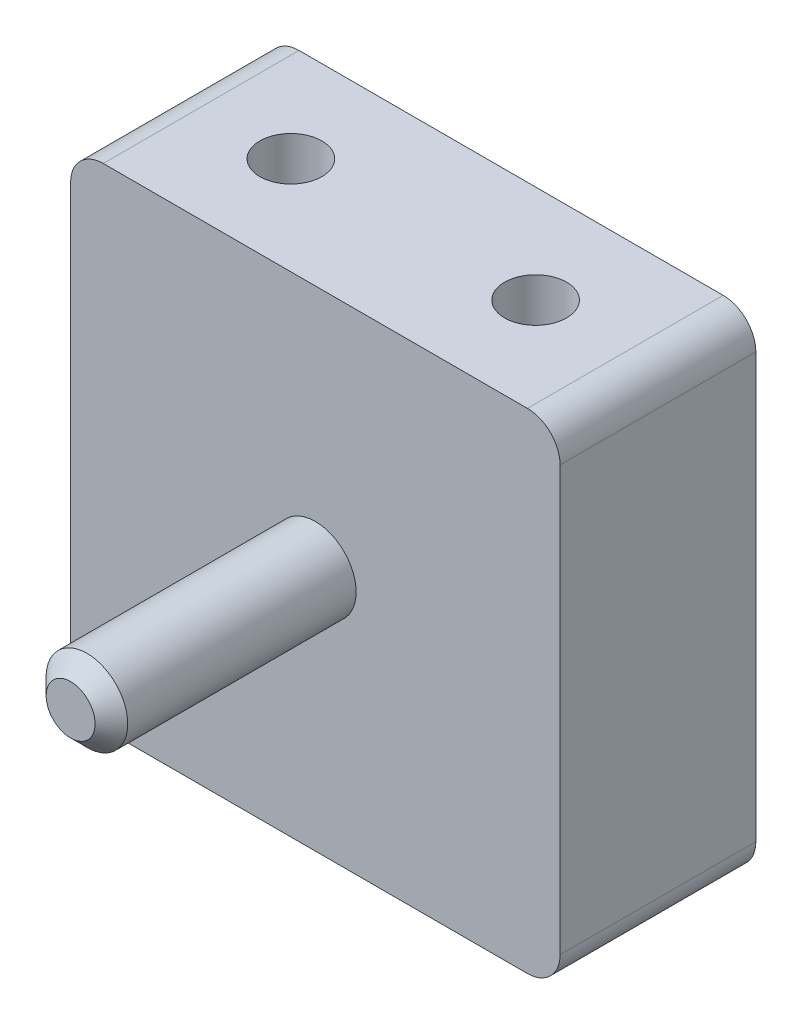
from build123d import *

# Parameters (mm, degrees)
SKETCH1_W           = 38.1
SKETCH1_H           = 38.1
SKETCH1_R           = 1.5875
BOSS_EXTRUDE2_DEPTH = 15.24
SKETCH3_R           = 3.175
BOSS_EXTRUDE3_DEPTH = 19.05
FILLET2_R           = 2.54
CHAMFER1_SIZE       = 1.27
SKETCH4_R           = 2.413
CUT_EXTRUDE2_DEPTH  = 7.62
SKETCH5_R           = 2.413
CUT_EXTRUDE3_DEPTH  = 7.62
SKETCH6_R           = 2.413
CUT_EXTRUDE4_DEPTH  = 39.1


with BuildPart() as part:
    # Sketch1 → Boss-Extrude2 (new body)
    with BuildSketch(Plane.XY):
        Rectangle(SKETCH1_W, SKETCH1_H)
        Circle(SKETCH1_R, mode=Mode.SUBTRACT)
    extrude(amount=BOSS_EXTRUDE2_DEPTH)

    # Sketch3 → Boss-Extrude3 (add)
    with BuildSketch(Plane.XY.offset(15.24)):
        Circle(SKETCH3_R)
    extrude(amount=BOSS_EXTRUDE3_DEPTH)

    # Fillet2
    fillet2_edges = [part.edges().sort_by_distance(p)[0] for p in [
        (-19.05, 19.05, 7.62),
        (19.05, 19.05, 7.62),
        (19.05, -19.05, 7.62),
        (-19.05, -19.05, 7.62),
    ]]
    fillet(fillet2_edges, radius=FILLET2_R)

    # Chamfer1
    chamfer1_edges = [part.edges().sort_by_distance(p)[0] for p in [
        (-3.175, 0, 34.29),
    ]]
    chamfer(chamfer1_edges, length=CHAMFER1_SIZE)

    # Sketch4 → Cut-Extrude2 (cut)
    with BuildSketch(Plane.XZ.offset(19.05)):
        with Locations((-9.525, 7.62)):
            Circle(SKETCH4_R)
        with Locations((9.525, 7.62)):
            Circle(SKETCH4_R)
    extrude(amount=-CUT_EXTRUDE2_DEPTH, mode=Mode.SUBTRACT)

    # Sketch5 → Cut-Extrude3 (cut)
    with BuildSketch(Plane(origin=(0, 19.05, 0), x_dir=(1, 0, 0), z_dir=(0, 1, 0))):
        with Locations((9.525, -7.62)):
            Circle(SKETCH5_R)
        with Locations((-9.525, -7.62)):
            Circle(SKETCH5_R)
    extrude(amount=-CUT_EXTRUDE3_DEPTH, mode=Mode.SUBTRACT)

    # Sketch6 → Cut-Extrude4 (cut, through all)
    with BuildSketch(Plane(origin=(0, 19.05, 0), x_dir=(1, 0, 0), z_dir=(0, 1, 0))):
        with Locations((9.525, -7.62)):
            Circle(SKETCH6_R)
        with Locations((-9.525, -7.62)):
            Circle(SKETCH6_R)
    extrude(amount=-CUT_EXTRUDE4_DEPTH, mode=Mode.SUBTRACT)


solid = part.part
